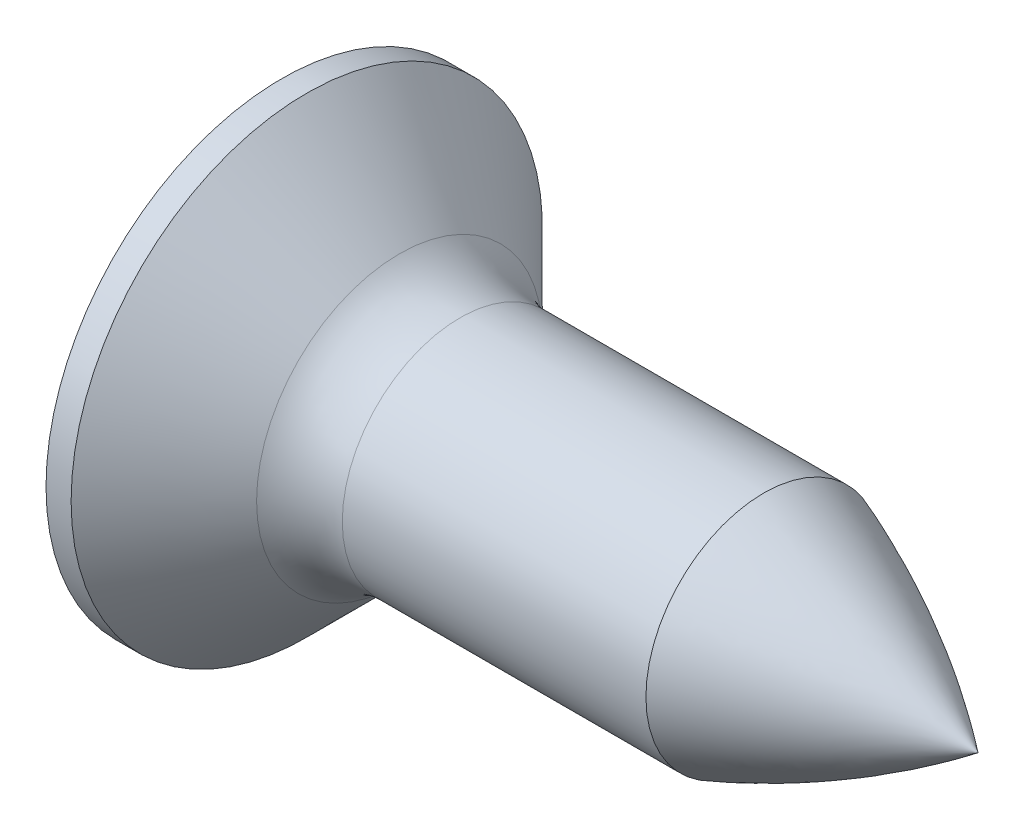
from build123d import *

# Parameters (mm, degrees)
CROSSRECESS_DEPTH = 1.2
DRAFT1_ANGLE      = -30


with BuildPart() as part:
    # Sketch1 → Base (revolve)
    with BuildSketch(Plane.XY):
        with BuildLine():
            Line((7, 0), (7, 1.1))
            Line((7, 1.1), (2.165685425, 1.1))
            ThreePointArc((2.165685425, 1.1), (1.859538679, 1.160896374), (1.6, 1.334314575))
            Line((1.6, 1.334314575), (0.734314575, 2.2))
            Line((0.734314575, 2.2), (0.5, 2.2))
            ThreePointArc((0.5, 2.2), (0.126573764, 1.128051417), (0, 0))
            Line((0, 0), (7, 0))
        make_face()
    revolve(axis=Axis((-20.418228315, 0, 0), (1, 0, 0)))

    # Sketch2 → CrossRecess (cut)
    with BuildSketch(Plane(origin=(0, 0, 0), x_dir=(0, 0, -1), z_dir=(1, 0, 0))):
        Polygon((-0.22, 1.1), (0.22, 1.1), (0.22, 0.22), (1.1, 0.22), (1.1, -0.22), (0.22, -0.22), (0.22, -1.1), (-0.22, -1.1), (-0.22, -0.22), (-1.1, -0.22), (-1.1, 0.22), (-0.22, 0.22), align=None)
    extrude(amount=CROSSRECESS_DEPTH, mode=Mode.SUBTRACT)

    # Sketch5 → Cut-Revolve6 (revolve, cut)
    with BuildSketch(Plane.XY):
        with BuildLine():
            Line((7, 0), (7.5, 0))
            Line((7.5, 0), (7.5, -1.1))
            Line((7.5, -1.1), (7, -1.1))
            Line((7, -1.1), (5, -1.1))
            ThreePointArc((5, -1.1), (6.03943286, -0.621696108), (7, 0))
        make_face()
    revolve(axis=Axis((37.040663239, 0, 0), (-1, 0, 0)), mode=Mode.SUBTRACT)

    # Draft1
    draft1_faces = [part.faces().sort_by_distance(p)[0] for p in [
        (0.660951691, -1.1, 0),
        (0.660951691, 0, -1.1),
        (0.660951691, 0, 1.1),
        (0.660951691, 1.1, 0),
    ]]
    draft(draft1_faces, Plane(origin=(0, 0, 0), x_dir=(0, 0, 1), z_dir=(1, 0, 0)), DRAFT1_ANGLE)


solid = part.part
